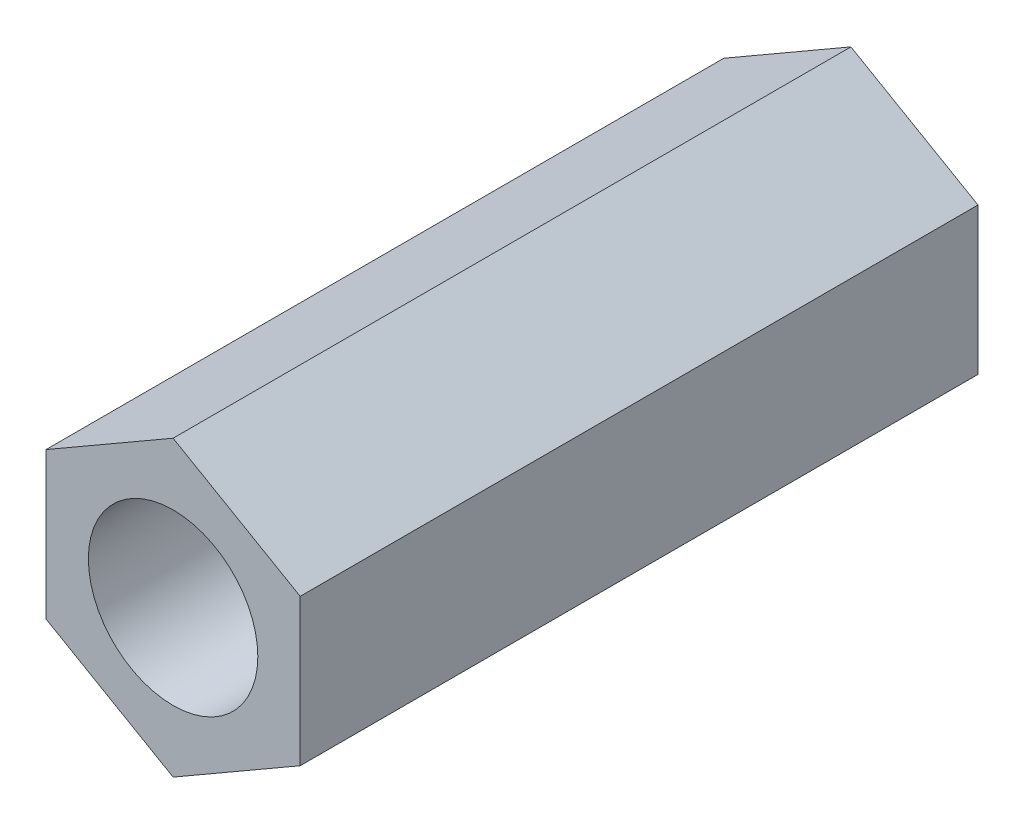
from build123d import *

# Parameters (mm, degrees)
SKETCH1_R           = 9.525
BOSS_EXTRUDE1_DEPTH = 76.2


with BuildPart() as part:
    # Sketch1 → Boss-Extrude1 (new body)
    with BuildSketch(Plane.XY):
        Polygon((14.2875, -8.248891971), (14.2875, 8.248891971), (0, 16.497783942), (-14.2875, 8.248891971), (-14.2875, -8.248891971), (0, -16.497783942), align=None)
        Circle(SKETCH1_R, mode=Mode.SUBTRACT)
    extrude(amount=BOSS_EXTRUDE1_DEPTH)


solid = part.part
